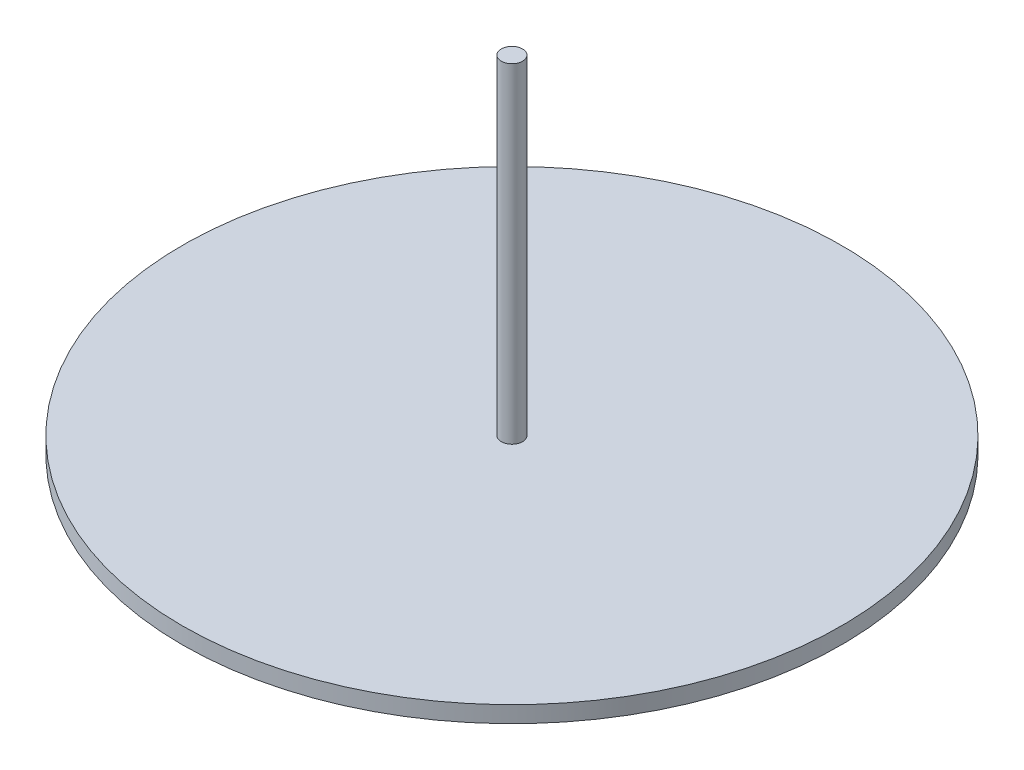
from build123d import *

# Parameters (mm, degrees)
SKETCH3_R           = 100
BOSS_EXTRUDE2_DEPTH = 5
SKETCH4_R           = 3.225
BOSS_EXTRUDE3_DEPTH = 100


with BuildPart() as part:
    # Sketch3 → Boss-Extrude2 (new body)
    with BuildSketch(Plane(origin=(0, 0, 0), x_dir=(1, 0, 0), z_dir=(0, 1, 0))):
        Circle(SKETCH3_R)
    extrude(amount=BOSS_EXTRUDE2_DEPTH)

    # Sketch4 → Boss-Extrude3 (add)
    with BuildSketch(Plane(origin=(0, 5, 0), x_dir=(1, 0, 0), z_dir=(0, 1, 0))):
        Circle(SKETCH4_R)
    extrude(amount=BOSS_EXTRUDE3_DEPTH)


solid = part.part
